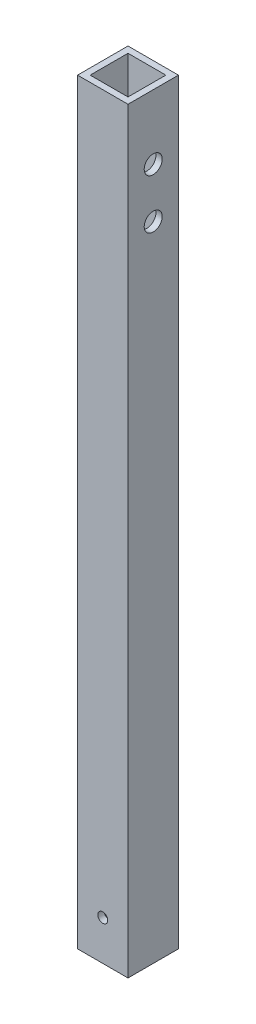
from build123d import *

# Parameters (mm, degrees)
SKETCH1_W           = 25.4
SKETCH1_H           = 25.4
SKETCH1_W_2         = 19.05
SKETCH1_H_2         = 19.05
BOSS_EXTRUDE1_DEPTH = 381
SKETCH2_R           = 2.5
CUT_EXTRUDE1_DEPTH  = 26.4
SKETCH3_R           = 4.539166488
CUT_EXTRUDE2_DEPTH  = 26.4


with BuildPart() as part:
    # Sketch1 → Boss-Extrude1 (new body)
    with BuildSketch(Plane(origin=(0, 0, 0), x_dir=(1, 0, 0), z_dir=(0, 1, 0))):
        Rectangle(SKETCH1_W, SKETCH1_H)
        Rectangle(SKETCH1_W_2, SKETCH1_H_2, mode=Mode.SUBTRACT)
    extrude(amount=BOSS_EXTRUDE1_DEPTH)

    # Sketch2 → Cut-Extrude1 (cut, through all)
    with BuildSketch(Plane(origin=(0, 0, -12.7), x_dir=(-1, 0, 0), z_dir=(0, 0, -1))):
        with Locations((0, 20)):
            Circle(SKETCH2_R)
    extrude(amount=-CUT_EXTRUDE1_DEPTH, mode=Mode.SUBTRACT)

    # Sketch3 → Cut-Extrude2 (cut, through all)
    with BuildSketch(Plane.ZY.offset(12.7)):
        with Locations((0, 348.5)):
            Circle(SKETCH3_R)
        with Locations((0, 323.5)):
            Circle(SKETCH3_R)
    extrude(amount=-CUT_EXTRUDE2_DEPTH, mode=Mode.SUBTRACT)


solid = part.part
